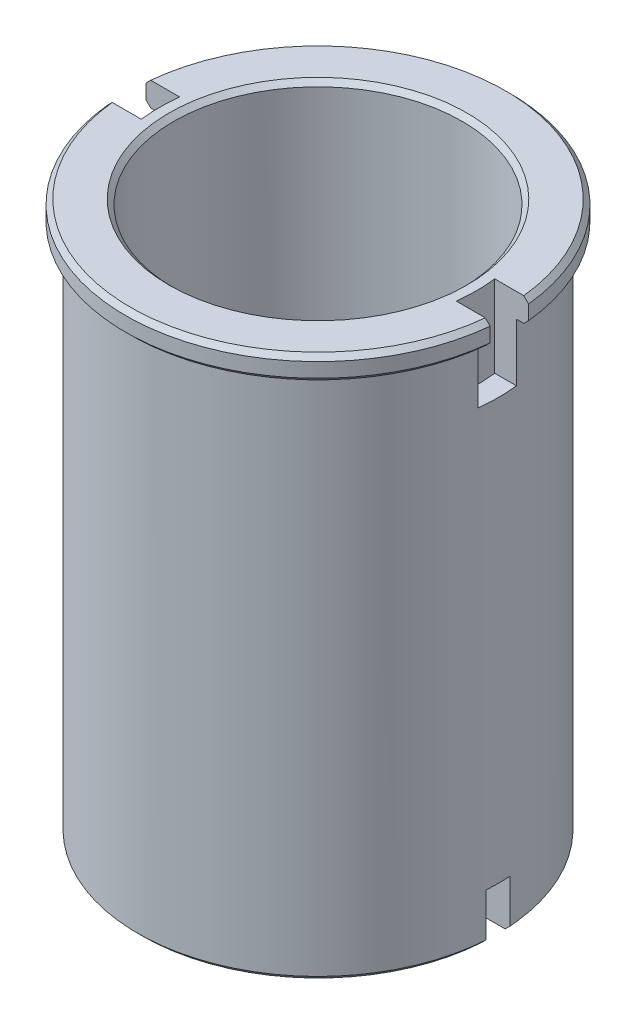
from build123d import *

# Parameters (mm, degrees)
SKETCH1_R           = 37.5
SKETCH1_R_2         = 30
BOSS_EXTRUDE1_DEPTH = 57.25
SKETCH2_R           = 40
SKETCH2_R_2         = 37.5
BOSS_EXTRUDE2_DEPTH = 5
SKETCH3_W           = 90
SKETCH3_H           = 5
CUT_EXTRUDE1_DEPTH  = 10
CUT_EXTRUDE2_DEPTH  = 17
CHAMFER1_SIZE       = 1


with BuildPart() as part:
    # Sketch1 → Boss-Extrude1 (new body, symmetric)
    with BuildSketch(Plane(origin=(0, 0, 0), x_dir=(1, 0, 0), z_dir=(0, 1, 0))):
        Circle(SKETCH1_R)
        Circle(SKETCH1_R_2, mode=Mode.SUBTRACT)
    extrude(amount=BOSS_EXTRUDE1_DEPTH, both=True)

    # Sketch2 → Boss-Extrude2 (add)
    with BuildSketch(Plane(origin=(0, 57.25, 0), x_dir=(1, 0, 0), z_dir=(0, 1, 0))):
        Circle(SKETCH2_R)
        Circle(SKETCH2_R_2, mode=Mode.SUBTRACT)
    extrude(amount=-BOSS_EXTRUDE2_DEPTH)

    # Sketch3 → Cut-Extrude1 (cut)
    with BuildSketch(Plane.XZ.offset(57.25)):
        Rectangle(SKETCH3_W, SKETCH3_H)
    extrude(amount=-CUT_EXTRUDE1_DEPTH, mode=Mode.SUBTRACT)

    # Sketch4 → Cut-Extrude2 (cut)
    with BuildSketch(Plane(origin=(0, 57.25, 0), x_dir=(1, 0, 0), z_dir=(0, 1, 0))):
        with BuildLine():
            Line((32.756678708, -4), (39.799497484, -4))
            ThreePointArc((39.799497484, -4), (39.949842924, -2.002511002), (40, 0))
            ThreePointArc((40, 0), (39.949842924, 2.002511002), (39.799497484, 4))
            Line((39.799497484, 4), (32.756678708, 4))
            ThreePointArc((32.756678708, 4), (32.939113508, 2.003696911), (33, 0))
            ThreePointArc((33, 0), (32.939113508, -2.003696911), (32.756678708, -4))
        make_face()
        with BuildLine():
            ThreePointArc((-39.799497484, 4), (-40, 0), (-39.799497484, -4))
            Line((-39.799497484, -4), (-32.756678708, -4))
            ThreePointArc((-32.756678708, -4), (-33, 0), (-32.756678708, 4))
            Line((-32.756678708, 4), (-39.799497484, 4))
        make_face()
    extrude(amount=-CUT_EXTRUDE2_DEPTH, mode=Mode.SUBTRACT)

    # Chamfer1
    chamfer1_edges = [part.edges().sort_by_distance(p)[0] for p in [
        (0, 57.25, 40),
        (-30, 57.25, 0),
        (0, -57.25, -30),
        (0, -57.25, 30),
        (0, -57.25, -37.5),
        (0, -57.25, 37.5),
        (0, 52.25, -40),
        (0, 52.25, 40),
        (0, 57.25, -40),
    ]]
    chamfer(chamfer1_edges, length=CHAMFER1_SIZE)


solid = part.part
